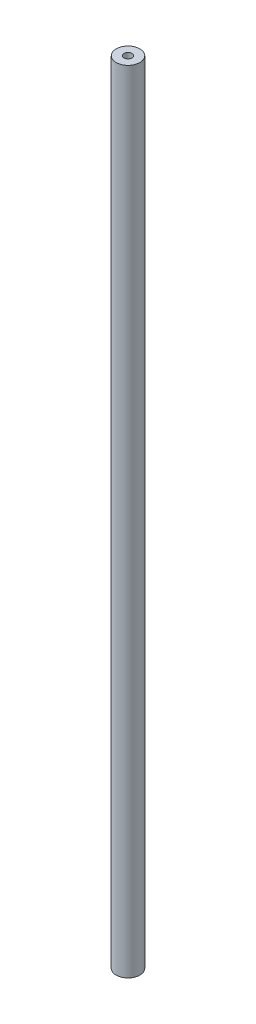
from build123d import *

# Parameters (mm, degrees)
SKETCH1_R   = 1.5
SKETCH1_R_2 = 0.5


with BuildPart() as part:
    # Sweep1: sweep along a path in Sketch2
    with BuildLine(Plane.XY) as sweep1_path:
        Line((0, 50.00015625), (0, -50.00015625))
    # Sketch1 → Sweep1 (sweep)
    with BuildSketch(Plane(origin=(0, 0, 0), x_dir=(1, 0, 0), z_dir=(0, 1, 0))):
        Circle(SKETCH1_R)
        Circle(SKETCH1_R_2, mode=Mode.SUBTRACT)
    sweep(path=sweep1_path.line)


solid = part.part
